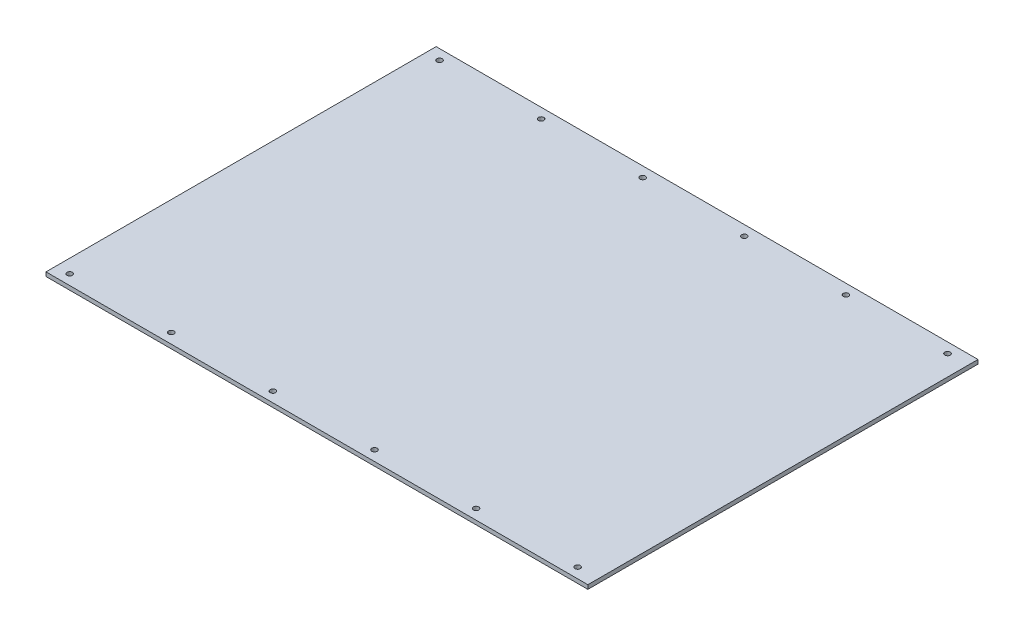
from build123d import *

# Parameters (mm, degrees)
SKETCH1_W           = 400
SKETCH1_H           = 288
BOSS_EXTRUDE1_DEPTH = 3
SKETCH2_R           = 2
CUT_EXTRUDE1_DEPTH  = 10


with BuildPart() as part:
    # Sketch1 → Boss-Extrude1 (new body)
    with BuildSketch(Plane(origin=(0, 0, 0), x_dir=(1, 0, 0), z_dir=(0, 1, 0))):
        Rectangle(SKETCH1_W, SKETCH1_H)
    extrude(amount=BOSS_EXTRUDE1_DEPTH)

    # Sketch2 → Cut-Extrude1 (cut)
    with BuildSketch(Plane(origin=(0, 3, 0), x_dir=(1, 0, 0), z_dir=(0, 1, 0))):
        with Locations((-190, 136.5)):
            Circle(SKETCH2_R)
        with Locations((-115, 136.5)):
            Circle(SKETCH2_R)
        with Locations((-40, 136.5)):
            Circle(SKETCH2_R)
        with Locations((35, 136.5)):
            Circle(SKETCH2_R)
        with Locations((110, 136.5)):
            Circle(SKETCH2_R)
        with Locations((185, 136.5)):
            Circle(SKETCH2_R)
        with Locations((185, -136.5)):
            Circle(SKETCH2_R)
        with Locations((110, -136.5)):
            Circle(SKETCH2_R)
        with Locations((35, -136.5)):
            Circle(SKETCH2_R)
        with Locations((-40, -136.5)):
            Circle(SKETCH2_R)
        with Locations((-115, -136.5)):
            Circle(SKETCH2_R)
        with Locations((-190, -136.5)):
            Circle(SKETCH2_R)
    extrude(amount=-CUT_EXTRUDE1_DEPTH, mode=Mode.SUBTRACT)


solid = part.part
